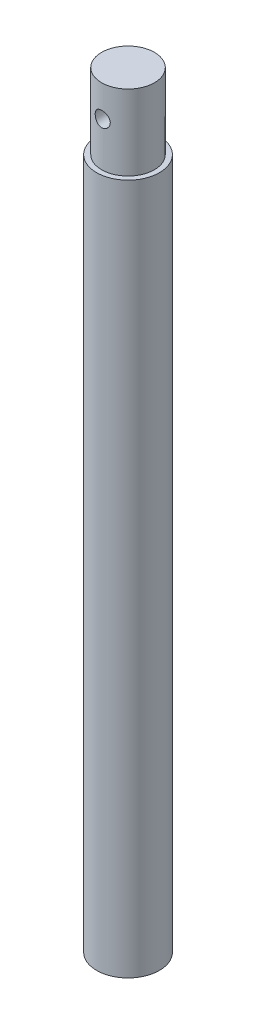
from build123d import *

# Parameters (mm, degrees)
SKETCH3_R          = 3
CUT_EXTRUDE1_DEPTH = 25


with BuildPart() as part:
    # Sketch2 → Revolve1 (revolve)
    with BuildSketch(Plane.XY):
        Polygon((0, 0), (12.5, 0), (12.5, 275), (10.5, 275), (10.5, 305), (0, 305), align=None)
    revolve(axis=Axis((0, 0, 0), (0, 1, 0)))

    # Sketch3 → Cut-Extrude1 (cut, symmetric)
    with BuildSketch(Plane.XY):
        with Locations((0, 292.5)):
            Circle(SKETCH3_R)
    extrude(amount=CUT_EXTRUDE1_DEPTH, both=True, mode=Mode.SUBTRACT)


solid = part.part
